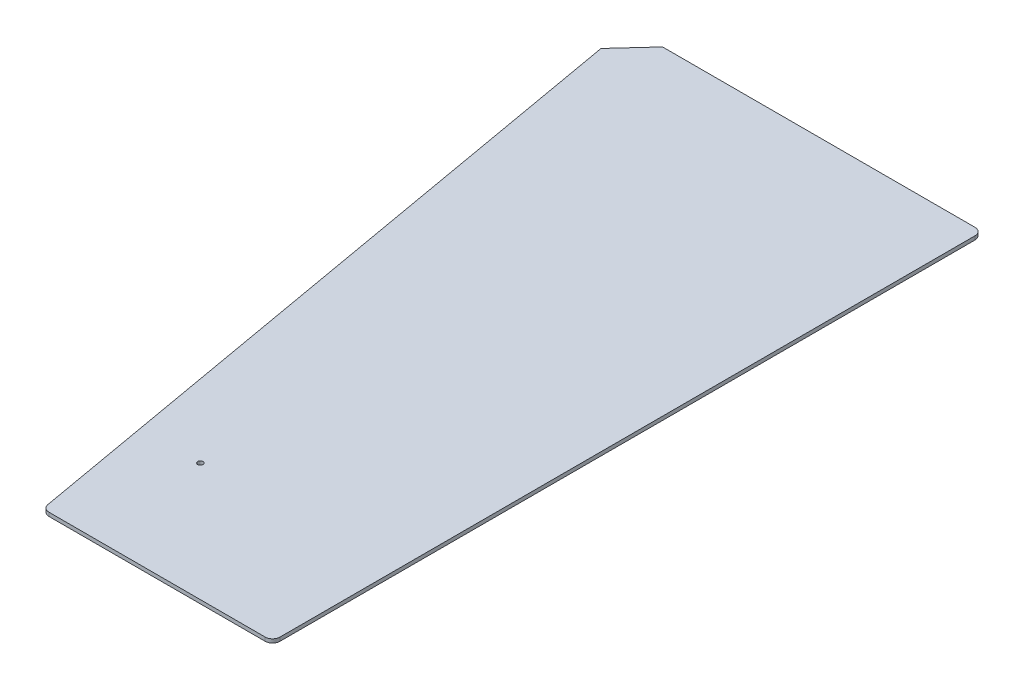
from build123d import *

# Parameters (mm, degrees)
STOCK_TO_SIZE_DEPTH = 3.175
SKETCH2_R           = 2.286
MOUNTING_HOLE_DEPTH = 4.175


with BuildPart() as part:
    # Sketch1 → Stock to Size (new body)
    with BuildSketch(Plane(origin=(0, 0, 0), x_dir=(1, 0, 0), z_dir=(0, 1, 0))):
        with BuildLine():
            Line((-72.207668016, -239.550243772), (113.425121886, -239.550243772))
            ThreePointArc((113.425121886, -239.550243772), (117.915249947, -237.690371833), (119.775121886, -233.200243772))
            Line((119.775121886, -233.200243772), (119.775121886, 363.699756228))
            ThreePointArc((119.775121886, 363.699756228), (117.915249947, 368.189884288), (113.425121886, 370.049756228))
            Line((113.425121886, 370.049756228), (-154.880183722, 370.049756228))
            Line((-154.880183722, 370.049756228), (-180.160298169, 342.461352424))
            Line((-180.160298169, 342.461352424), (-78.461197248, -234.302909701))
            ThreePointArc((-78.461197248, -234.302909701), (-76.289369337, -238.064625986), (-72.207668016, -239.550243772))
        make_face()
    extrude(amount=STOCK_TO_SIZE_DEPTH)

    # Sketch2 → Mounting Hole (cut, through all)
    with BuildSketch(Plane(origin=(0, 3.175, 0), x_dir=(1, 0, 0), z_dir=(0, 1, 0))):
        with Locations((-43.86710003, -137.950243772)):
            Circle(SKETCH2_R)
    extrude(amount=-MOUNTING_HOLE_DEPTH, mode=Mode.SUBTRACT)


solid = part.part
